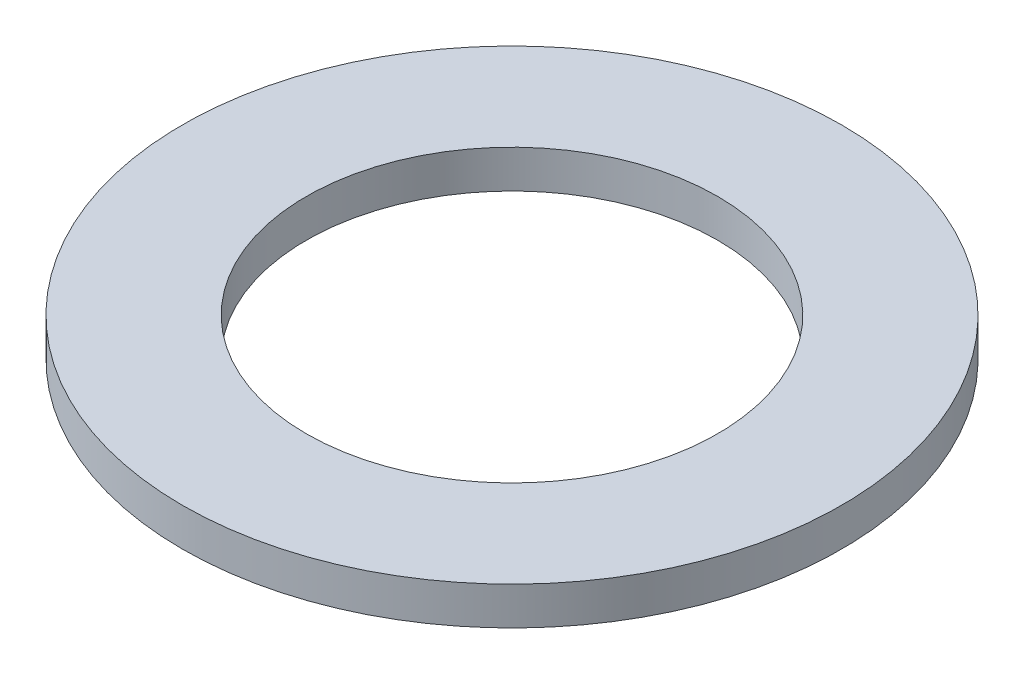
from build123d import *

# Parameters (mm, degrees)
SKETCH1_R           = 7.9375
BOSS_EXTRUDE1_DEPTH = 0.9144
SKETCH5_R           = 4.953
CUT_EXTRUDE1_DEPTH  = 1.9144


with BuildPart() as part:
    # Sketch1 → Boss-Extrude1 (new body)
    with BuildSketch(Plane(origin=(0, 0, 0), x_dir=(1, 0, 0), z_dir=(0, 1, 0))):
        Circle(SKETCH1_R)
    extrude(amount=BOSS_EXTRUDE1_DEPTH)

    # Sketch5 → Cut-Extrude1 (cut, through all)
    with BuildSketch(Plane(origin=(0, 0.9144, 0), x_dir=(-1, 0, 0), z_dir=(0, 1, 0))):
        Circle(SKETCH5_R)
    extrude(amount=-CUT_EXTRUDE1_DEPTH, mode=Mode.SUBTRACT)


solid = part.part
